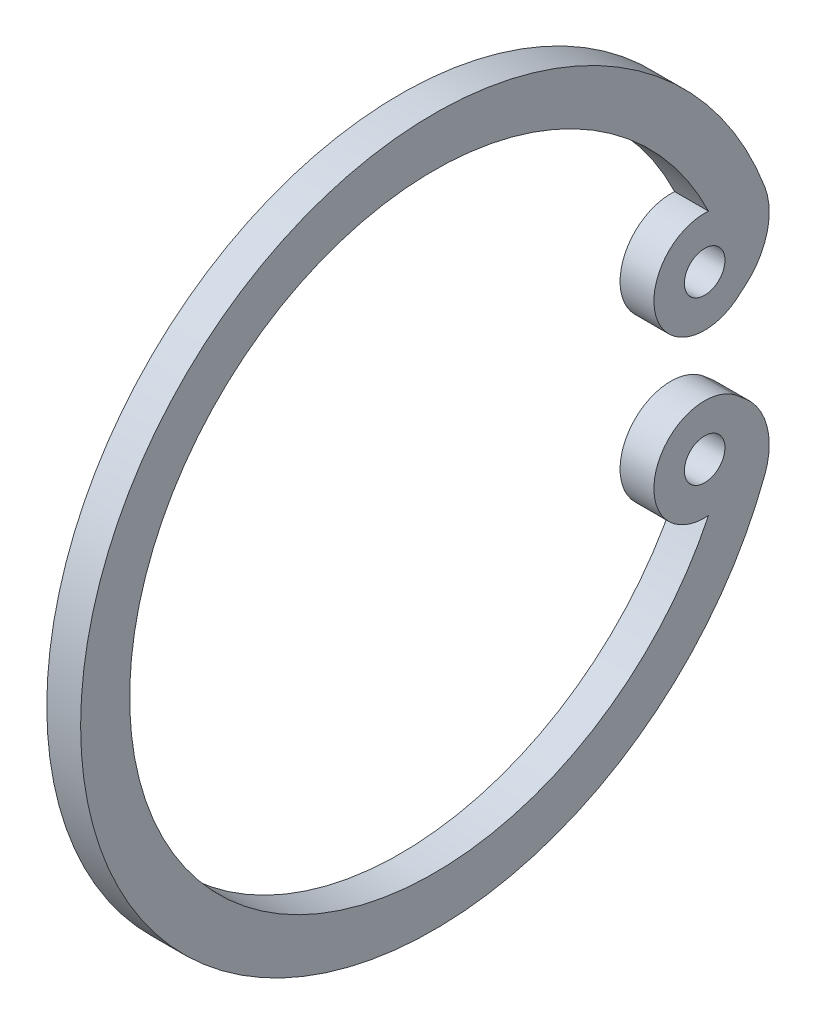
from build123d import *

# Parameters (mm, degrees)
SKETCH1_R           = 0.6
BOSS_EXTRUDE1_DEPTH = 1
SCALE2_SCALE        = 0.277777778


with BuildPart() as part:
    # Sketch1 → Boss-Extrude1 (new body)
    with BuildSketch(Plane(origin=(19, 0, 0), x_dir=(0, 0, -1), z_dir=(1, 0, 0))):
        with BuildLine():
            Line((-1.082906578, 1.214226965), (-0.806260325, 1.444819657))
            ThreePointArc((-0.806260325, 1.444819657), (-0.157167996, 2.46989624), (-0.220083072, 3.681566388))
            ThreePointArc((-0.220083072, 3.681566388), (-20.449170804, -0.000103807), (-0.220095755, -3.681843689))
            ThreePointArc((-0.220095755, -3.681843689), (-0.157177378, -2.470170425), (-0.806270581, -1.44509051))
            Line((-0.806270581, -1.44509051), (-1.082193901, -1.213563353))
            ThreePointArc((-1.082193901, -1.213563353), (-3.437745717, -1.969386585), (-1.886859109, -3.896727719))
            ThreePointArc((-1.886859109, -3.896727719), (-18.999593972, -0.000121806), (-1.886859109, 3.896484108))
            ThreePointArc((-1.886859109, 3.896484108), (-3.437385157, 1.97013231), (-1.082906578, 1.214226965))
        make_face()
        with Locations((-2.00000003, -2.4)):
            Circle(SKETCH1_R, mode=Mode.SUBTRACT)
        with Locations((-2.00000003, 2.4)):
            Circle(SKETCH1_R, mode=Mode.SUBTRACT)
    extrude(amount=-BOSS_EXTRUDE1_DEPTH)


with BuildPart() as part_1:
    # Scale2: scaled about (18.5, -0.000178585, 9.916688181)
    add(part.part.scale(SCALE2_SCALE).moved(Location((13.361111111, -0.000128978, 7.162052575))))


solid = part_1.part
